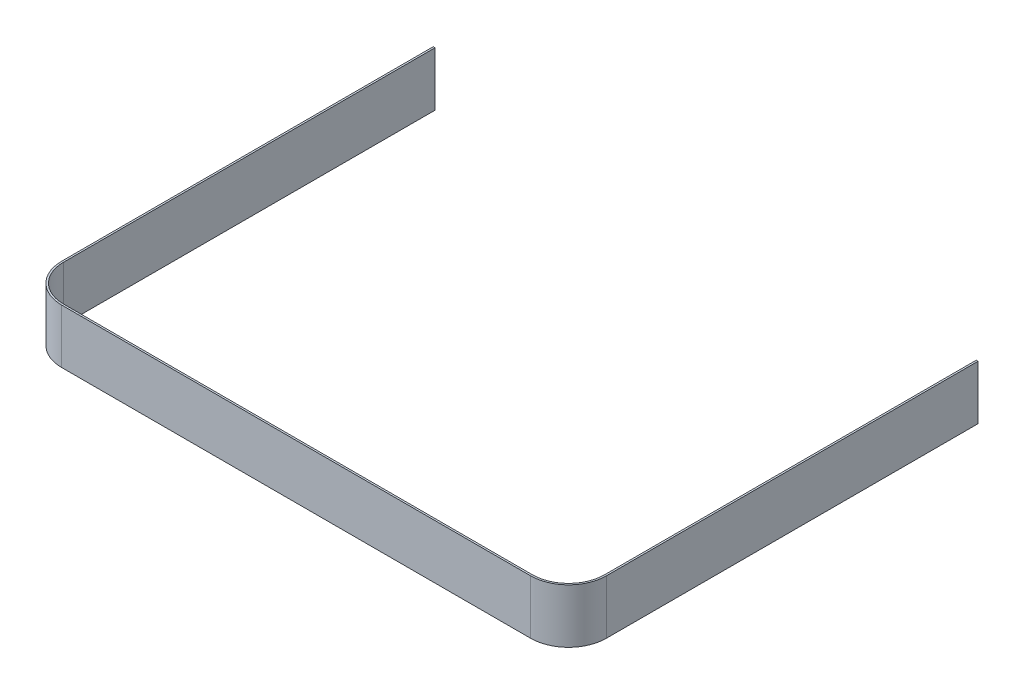
from build123d import *

# Parameters (mm, degrees)
LINEAR_AUSTRAGEN_D_NN1_DEPTH = 30


with BuildPart() as part:
    # Skizze1 → Linear-Austragen-Dünn1 (new body)
    with BuildSketch(Plane.XZ):
        with BuildLine():
            Line((0, 75), (130, 75))
            ThreePointArc((130, 75), (144.142135624, 69.142135624), (150, 55))
            Line((150, 55), (150, -150))
            Line((150, -150), (150, -151))
            Line((150, -151), (151, -151))
            Line((151, -151), (151, -150))
            Line((151, -150), (151, 55))
            ThreePointArc((151, 55), (144.849242405, 69.849242405), (130, 76))
            Line((130, 76), (0, 76))
            Line((0, 76), (0, 75))
        make_face()
    linear_austragen_d_nn1 = extrude(amount=-LINEAR_AUSTRAGEN_D_NN1_DEPTH)

    # Spiegeln1: Linear-Austragen-Dünn1 across plane
    add(linear_austragen_d_nn1.mirror(Plane(origin=(0, 30, 75), x_dir=(0, 0, 1), z_dir=(1, 0, 0))))


solid = part.part
